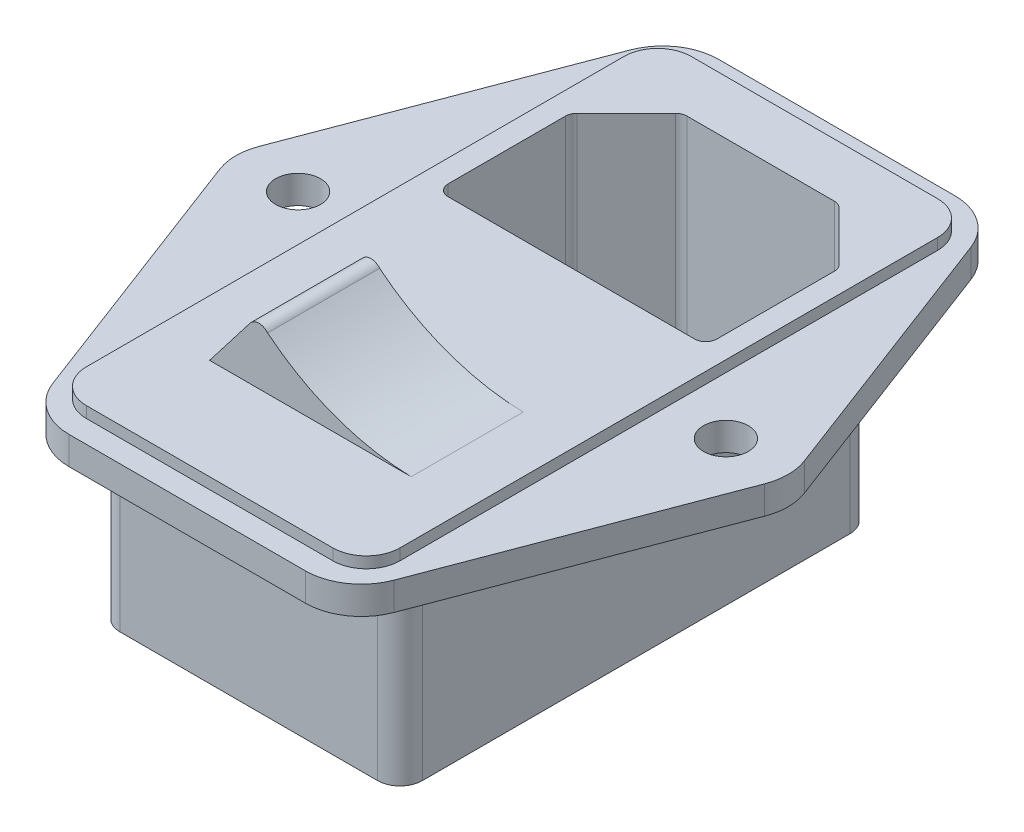
from build123d import *

# Parameters (mm, degrees)
SKETCH1_R           = 2
BOSS_EXTRUDE1_DEPTH = 2.5
FILLET1_R           = 5
BOSS_EXTRUDE2_DEPTH = 1
BOSS_EXTRUDE3_DEPTH = 16
FILLET2_R           = 2
CUT_EXTRUDE1_DEPTH  = 18
FILLET3_R           = 1
BOSS_EXTRUDE4_START = 8
BOSS_EXTRUDE4_DEPTH = 10


with BuildPart() as part:
    # Sketch1 → Boss-Extrude1 (new body)
    with BuildSketch(Plane(origin=(0, 0, 0), x_dir=(1, 0, 0), z_dir=(0, 1, 0))):
        Polygon((25, 0), (14, -29), (0, -29), (0, 29), (14, 29), align=None)
        with Locations((19.1, 0)):
            Circle(SKETCH1_R, mode=Mode.SUBTRACT)
    extrude(amount=-BOSS_EXTRUDE1_DEPTH)

    # Fillet1
    fillet1_edges = [part.edges().sort_by_distance(p)[0] for p in [
        (14, -1.25, -29),
        (25, -1.25, 0),
        (14, -1.25, 29),
    ]]
    fillet(fillet1_edges, radius=FILLET1_R)

    # Sketch2 → Boss-Extrude2 (add)
    with BuildSketch(Plane(origin=(0, 0, 0), x_dir=(1, 0, 0), z_dir=(0, 1, 0))):
        with BuildLine():
            Line((0, 27), (11, 27))
            ThreePointArc((11, 27), (13.121320344, 26.121320344), (14, 24))
            Line((14, 24), (14, -24))
            ThreePointArc((14, -24), (13.121320344, -26.121320344), (11, -27))
            Line((11, -27), (0, -27))
            Line((0, -27), (0, 27))
        make_face()
    extrude(amount=BOSS_EXTRUDE2_DEPTH)

    # Sketch3 → Boss-Extrude3 (add)
    with BuildSketch(Plane.XZ.offset(2.5)):
        Polygon((0, 23.5), (13.5, 23.5), (13.5, -17.5), (7.5, -23.5), (0, -23.5), align=None)
    extrude(amount=BOSS_EXTRUDE3_DEPTH)

    # Fillet2
    fillet2_edges = [part.edges().sort_by_distance(p)[0] for p in [
        (13.5, -10.5, -17.5),
        (7.5, -10.5, -23.5),
        (13.5, -10.5, 23.5),
    ]]
    fillet(fillet2_edges, radius=FILLET2_R)

    # Sketch5 → Cut-Extrude1 (cut)
    with BuildSketch(Plane(origin=(0, 1, 0), x_dir=(1, 0, 0), z_dir=(0, 1, 0))):
        Polygon((0, 22.2), (7, 22.2), (12, 17.2), (12, 5.3), (0, 5.3), align=None)
    extrude(amount=-CUT_EXTRUDE1_DEPTH, mode=Mode.SUBTRACT)

    # Fillet3
    fillet3_edges = [part.edges().sort_by_distance(p)[0] for p in [
        (7, -8, -22.2),
        (12, -8, -17.2),
        (12, -8, -5.3),
    ]]
    fillet(fillet3_edges, radius=FILLET3_R)

    # Mirror1: part across plane


with BuildPart() as part_1:
    add(part.part)
    add(part.part.mirror(Plane(origin=(0, -2.5, -29), x_dir=(0, 0, 1), z_dir=(-1, 0, 0))))

    # Sketch6 → Boss-Extrude4 (add)
    with BuildSketch(Plane.XY.offset(BOSS_EXTRUDE4_START)):
        with BuildLine():
            Line((-9, 1), (-5.383132121, 5.683158511))
            ThreePointArc((-5.383132121, 5.683158511), (-4.605403481, 6.071821883), (-3.817307634, 5.704635295))
            ThreePointArc((-3.817307634, 5.704635295), (2.199237296, 2.28405626), (9, 1))
            Line((9, 1), (-9, 1))
        make_face()
    extrude(amount=BOSS_EXTRUDE4_DEPTH)


solid = part_1.part
